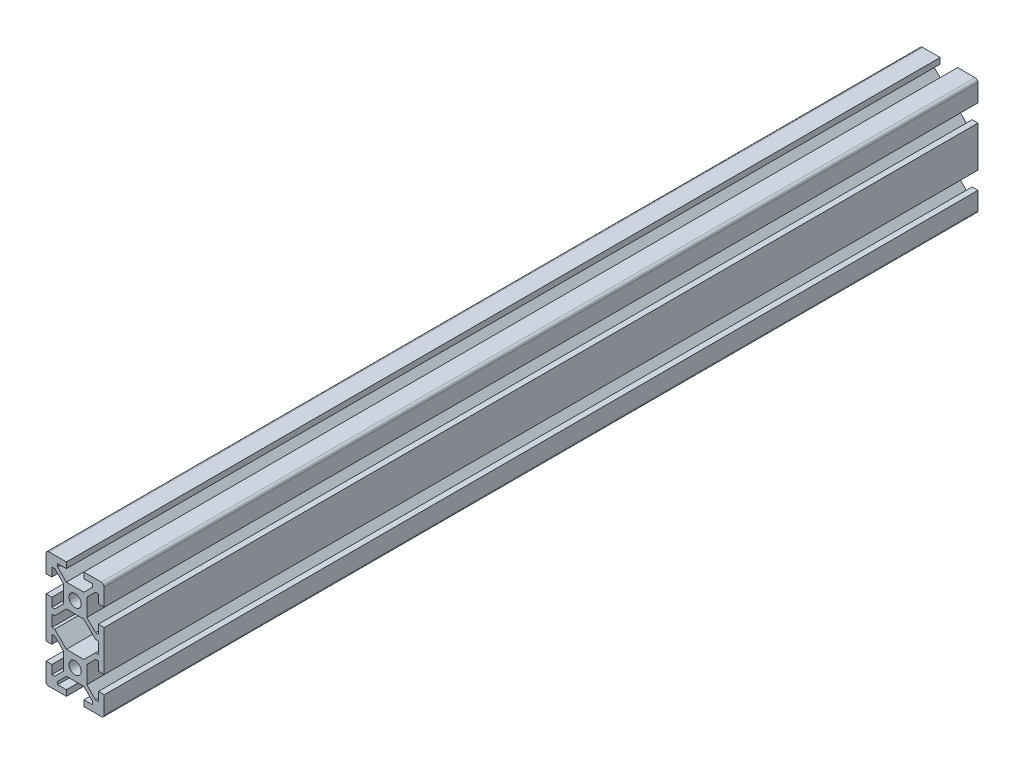
from build123d import *

# Parameters (mm, degrees)
SCHIZZO1_R                   = 2.1
ESTRUSIONE_ESTRUSIONE1_DEPTH = 300
RACCORDO1_R                  = 1


with BuildPart() as part:
    # Schizzo1 → Estrusione-Estrusione1 (new body)
    with BuildSketch(Plane.XY):
        Polygon((-3, 20), (-10, 20), (-10, 13), (-8, 13), (-8, 16), (-7, 16), (-4, 13), (-4, 7), (-7, 4), (-8, 4), (-8, 7), (-10, 7), (-10, -7), (-8, -7), (-8, -4), (-7, -4), (-4, -7), (-4, -13), (-7, -16), (-8, -16), (-8, -13), (-10, -13), (-10, -20), (-3, -20), (-3, -18), (-6, -18), (-6, -17), (-3, -14), (3, -14), (6, -17), (6, -18), (3, -18), (3, -20), (10, -20), (10, -13), (8, -13), (8, -16), (7, -16), (4, -13), (4, -7), (7, -4), (8, -4), (8, -7), (10, -7), (10, 7), (8, 7), (8, 4), (7, 4), (4, 7), (4, 13), (7, 16), (8, 16), (8, 13), (10, 13), (10, 20), (3, 20), (3, 18), (6, 18), (6, 17), (3, 14), (-3, 14), (-6, 17), (-6, 18), (-3, 18), align=None)
        Polygon((8, 2), (8, -2), (7, -2), (3, -6), (-3, -6), (-7, -2), (-8, -2), (-8, 2), (-7, 2), (-3, 6), (3, 6), (7, 2), align=None, mode=Mode.SUBTRACT)
        with Locations((0, 10)):
            Circle(SCHIZZO1_R, mode=Mode.SUBTRACT)
        with Locations((0, -10)):
            Circle(SCHIZZO1_R, mode=Mode.SUBTRACT)
    extrude(amount=ESTRUSIONE_ESTRUSIONE1_DEPTH)

    # Raccordo1
    raccordo1_edges = [part.edges().sort_by_distance(p)[0] for p in [
        (-10, 20, 150),
        (10, 20, 150),
        (10, -20, 150),
        (-10, -20, 150),
    ]]
    fillet(raccordo1_edges, radius=RACCORDO1_R)


solid = part.part
